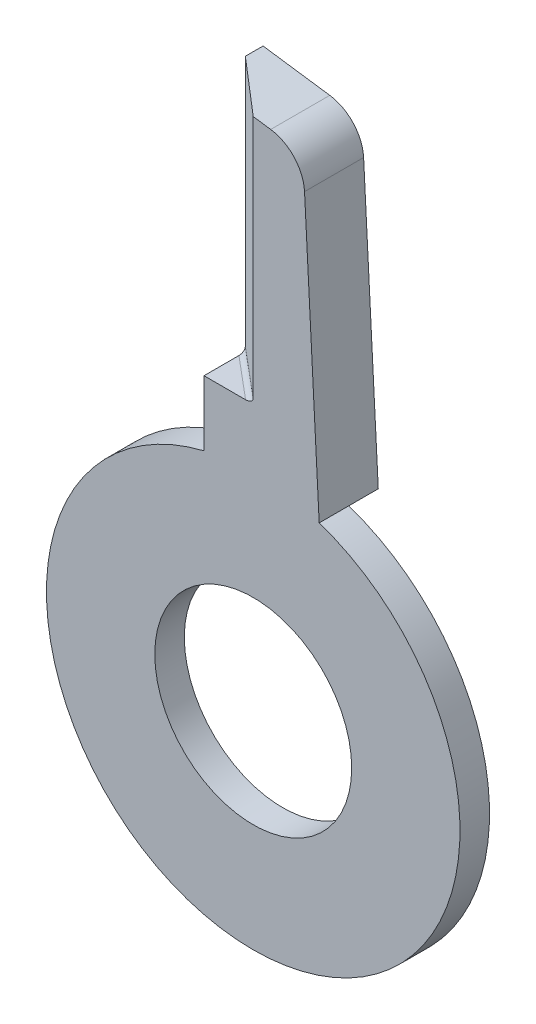
from build123d import *

# Parameters (mm, degrees)
CROQUIS1_R              = 10
SALIENTE_EXTRUIR1_DEPTH = 6
CROQUIS2_R              = 21
CROQUIS2_R_2            = 10
CORTAR_EXTRUIR1_DEPTH   = 3
CORTAR_EXTRUIR2_DEPTH   = 26
REDONDEO1_R             = 0.5


with BuildPart() as part:
    # Croquis1 → Saliente-Extruir1 (new body)
    with BuildSketch(Plane.XY):
        with BuildLine():
            Line((-5, 20.396078054), (-5, 53))
            Line((-5, 53), (1.774122543, 52.047959163))
            ThreePointArc((1.774122543, 52.047959163), (4.166539486, 50.789247719), (5.211948278, 48.296230713))
            Line((5.211948278, 48.296230713), (6.7, 19.902512404))
            ThreePointArc((6.7, 19.902512404), (-0.88509986, -20.981339286), (-5, 20.396078054))
        make_face()
        Circle(CROQUIS1_R, mode=Mode.SUBTRACT)
    extrude(amount=SALIENTE_EXTRUIR1_DEPTH)

    # Croquis2 → Cortar-Extruir1 (cut)
    with BuildSketch(Plane(origin=(0, 0, 0), x_dir=(-1, 0, 0), z_dir=(0, 0, -1))):
        Circle(CROQUIS2_R)
        Circle(CROQUIS2_R_2, mode=Mode.SUBTRACT)
    extrude(amount=-CORTAR_EXTRUIR1_DEPTH, mode=Mode.SUBTRACT)

    # Croquis3 → Cortar-Extruir2 (cut)
    with BuildSketch(Plane(origin=(0, 53, 0), x_dir=(-1, 0, 0), z_dir=(0, 1, 0))):
        Polygon((5, 6), (5, 1.8), (0, 6), align=None)
    extrude(amount=-CORTAR_EXTRUIR2_DEPTH, mode=Mode.SUBTRACT)

    # Redondeo1
    redondeo1_edges = [part.edges().sort_by_distance(p)[0] for p in [
        (-2.5, 27, 3.9),
    ]]
    fillet(redondeo1_edges, radius=REDONDEO1_R)


solid = part.part
